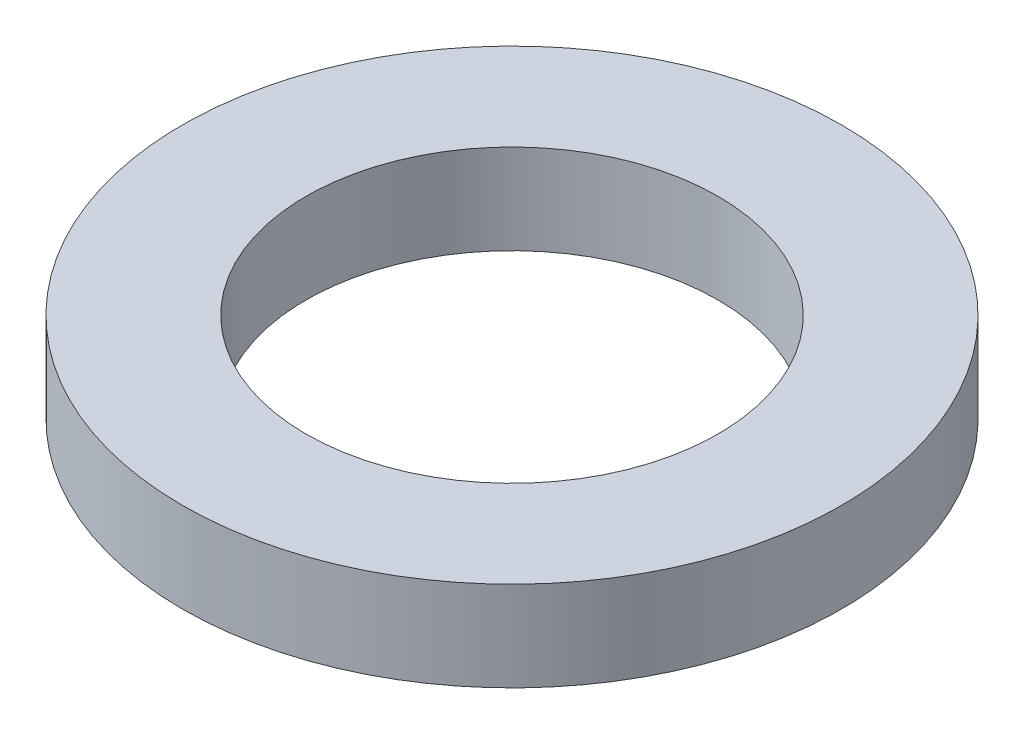
from build123d import *

# Parameters (mm, degrees)
ESQUISSE1_R        = 4
ESQUISSE1_R_2      = 2.5
BOSS_EXTRU_1_DEPTH = 1.09


with BuildPart() as part:
    # Esquisse1 → Boss.-Extru.1 (new body)
    with BuildSketch(Plane(origin=(0, 0, 0), x_dir=(1, 0, 0), z_dir=(0, 1, 0))):
        Circle(ESQUISSE1_R)
        Circle(ESQUISSE1_R_2, mode=Mode.SUBTRACT)
    extrude(amount=BOSS_EXTRU_1_DEPTH)


solid = part.part
